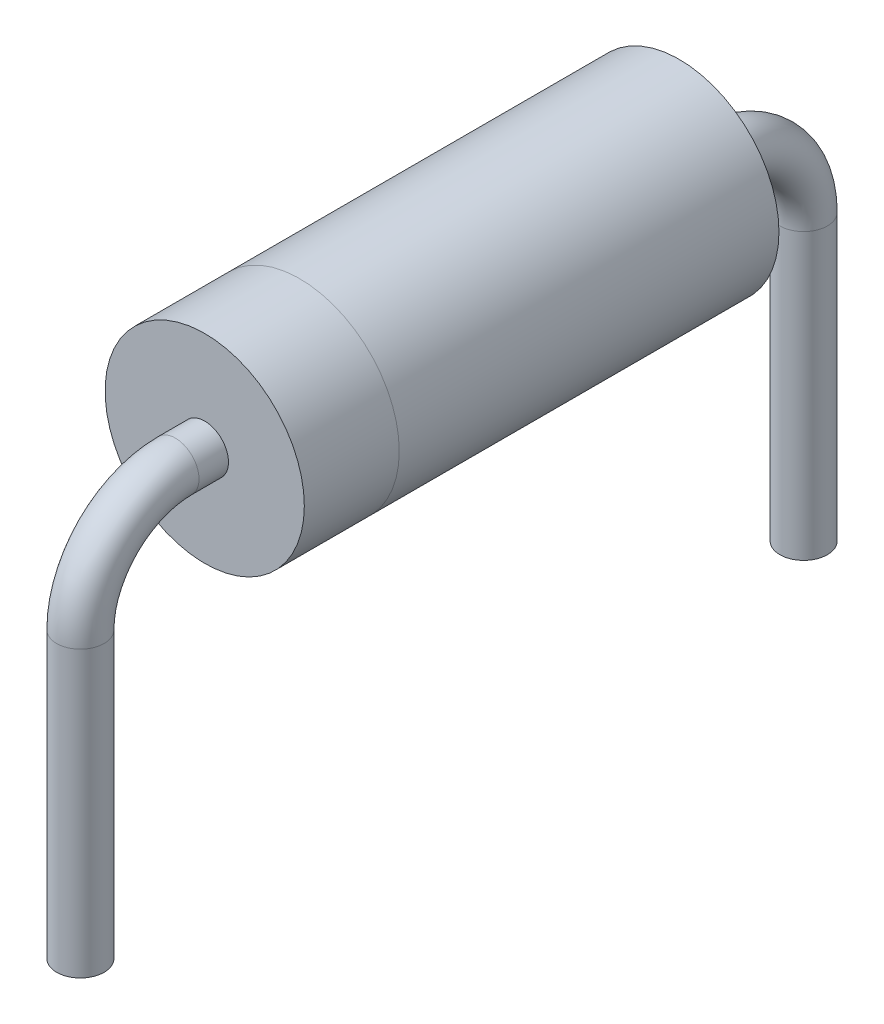
from build123d import *

# Parameters (mm, degrees)
ESQUISSE1_R        = 1.05
BOSS_EXTRU_1_DEPTH = 4
ESQUISSE2_R        = 1.0495
BOSS_EXTRU_2_DEPTH = 1
ESQUISSE4_R        = 0.25


with BuildPart() as part:
    # Esquisse1 → Boss.-Extru.1 (new body)
    with BuildSketch(Plane.XY):
        Circle(ESQUISSE1_R)
    extrude(amount=BOSS_EXTRU_1_DEPTH)

    # Esquisse2 → Boss.-Extru.2 (add)
    with BuildSketch(Plane.XY.offset(4)):
        Circle(ESQUISSE2_R)
    extrude(amount=BOSS_EXTRU_2_DEPTH)

    # Balayage1: sweep along a path in Esquisse3
    with BuildLine(Plane(origin=(0, 0, 0), x_dir=(0, 0, -1), z_dir=(1, 0, 0))) as balayage1_path:
        Line((-5, 0), (-5.31, 0))
        ThreePointArc((-5.31, 0), (-6.017106781, -0.292893219), (-6.31, -1))
        Line((-6.31, -1), (-6.31, -4))
    # Esquisse4 → Balayage1 (sweep)
    with BuildSketch(Plane.XY.offset(5)):
        Circle(ESQUISSE4_R)
    balayage1 = sweep(path=balayage1_path.line)

    # Symétrie1: Balayage1 across plane
    add(balayage1.mirror(Plane.XY.offset(2.5)))


solid = part.part
